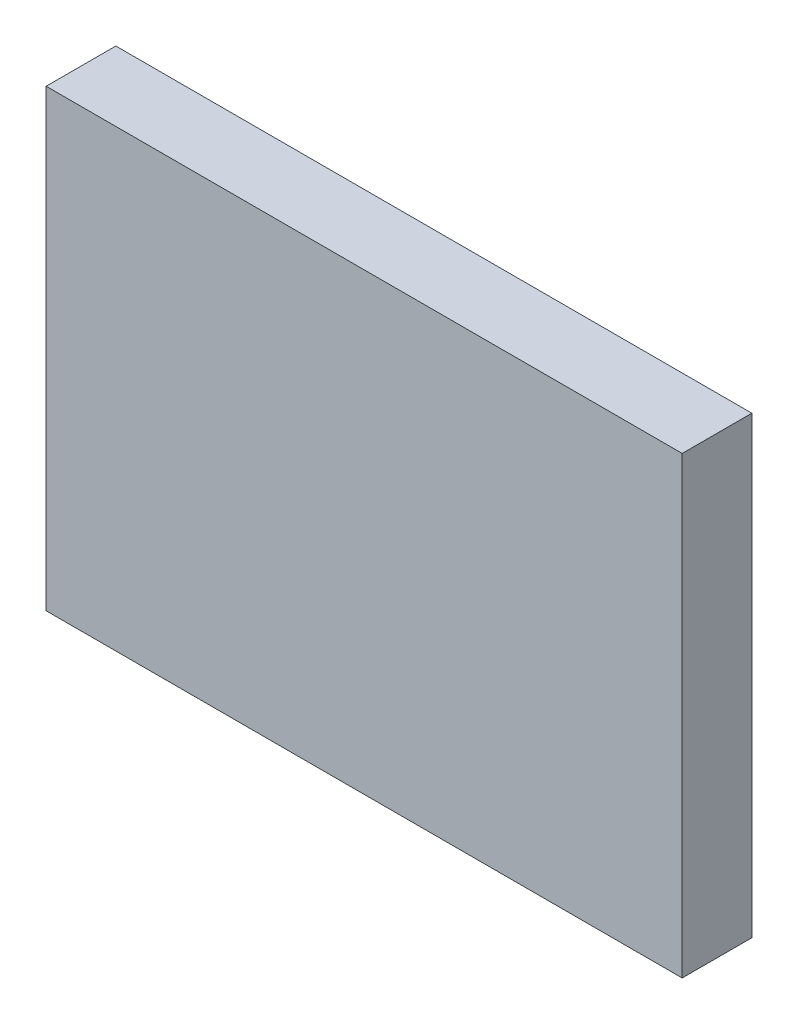
from build123d import *

# Parameters (mm, degrees)
SKETCH_1_W      = 21
SKETCH_1_H      = 15
EXTRUDE_1_DEPTH = 2.3


with BuildPart() as part:
    # 草图1 → 凸台-拉伸1 (new body)
    with BuildSketch(Plane.XY):
        with Locations((54.307491971, 30.781620917)):
            Rectangle(SKETCH_1_W, SKETCH_1_H)
    extrude(amount=EXTRUDE_1_DEPTH)


solid = part.part
